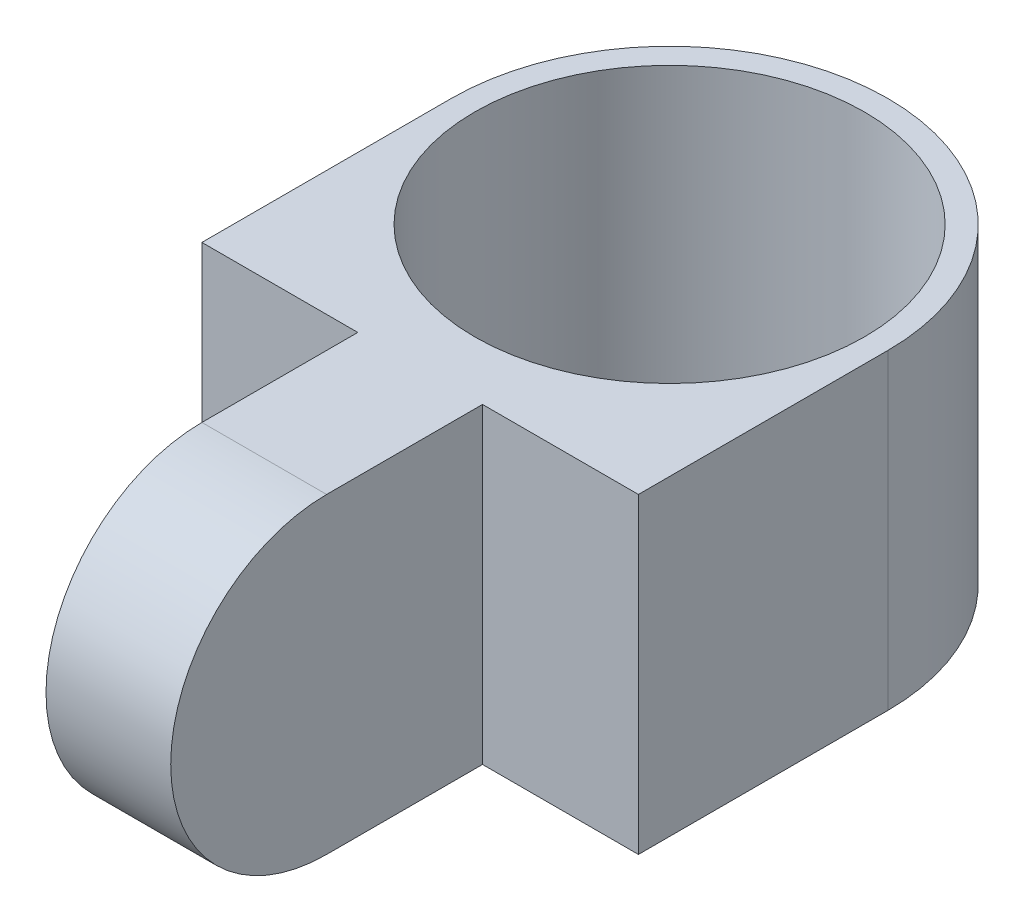
from build123d import *

# Parameters (mm, degrees)
SKETCH1_R                = 7
SKETCH1_R_2              = 6.25
BOSS_EXTRUDE1_DEPTH      = 10
SKETCH3_W                = 14
SKETCH3_H                = 10
BOSS_EXTRUDE2_DEPTH      = 8
SKETCH4_R                = 6.25
CUT_EXTRUDE1_DEPTH       = 20
BOSS_EXTRUDE3_DEPTH      = 2
BOSS_EXTRUDE3_DEPTH_BACK = 2


with BuildPart() as part:
    # Sketch1 → Boss-Extrude1 (new body)
    with BuildSketch(Plane(origin=(0, 0, 0), x_dir=(1, 0, 0), z_dir=(0, 1, 0))):
        Circle(SKETCH1_R)
        Circle(SKETCH1_R_2, mode=Mode.SUBTRACT)
    extrude(amount=BOSS_EXTRUDE1_DEPTH)

    # Sketch3 → Boss-Extrude2 (add)
    with BuildSketch(Plane.XY):
        with Locations((0, 5)):
            Rectangle(SKETCH3_W, SKETCH3_H)
    extrude(amount=BOSS_EXTRUDE2_DEPTH)

    # Sketch4 → Cut-Extrude1 (cut)
    with BuildSketch(Plane(origin=(0, 10, 0), x_dir=(1, 0, 0), z_dir=(0, 1, 0))):
        Circle(SKETCH4_R)
    extrude(amount=-CUT_EXTRUDE1_DEPTH, mode=Mode.SUBTRACT)

    # Sketch6 → Boss-Extrude3 (add, two sides)
    with BuildSketch(Plane(origin=(0, 0, 0), x_dir=(0, 0, -1), z_dir=(1, 0, 0))) as boss_extrude3_sk:
        with BuildLine():
            Line((-8, 10), (-13, 10))
            ThreePointArc((-13, 10), (-18, 5), (-13, 0))
            Line((-13, 0), (-8, 0))
            Line((-8, 0), (-8, 10))
        make_face()
    extrude(amount=BOSS_EXTRUDE3_DEPTH)
    extrude(boss_extrude3_sk.sketch, amount=-BOSS_EXTRUDE3_DEPTH_BACK)


solid = part.part
